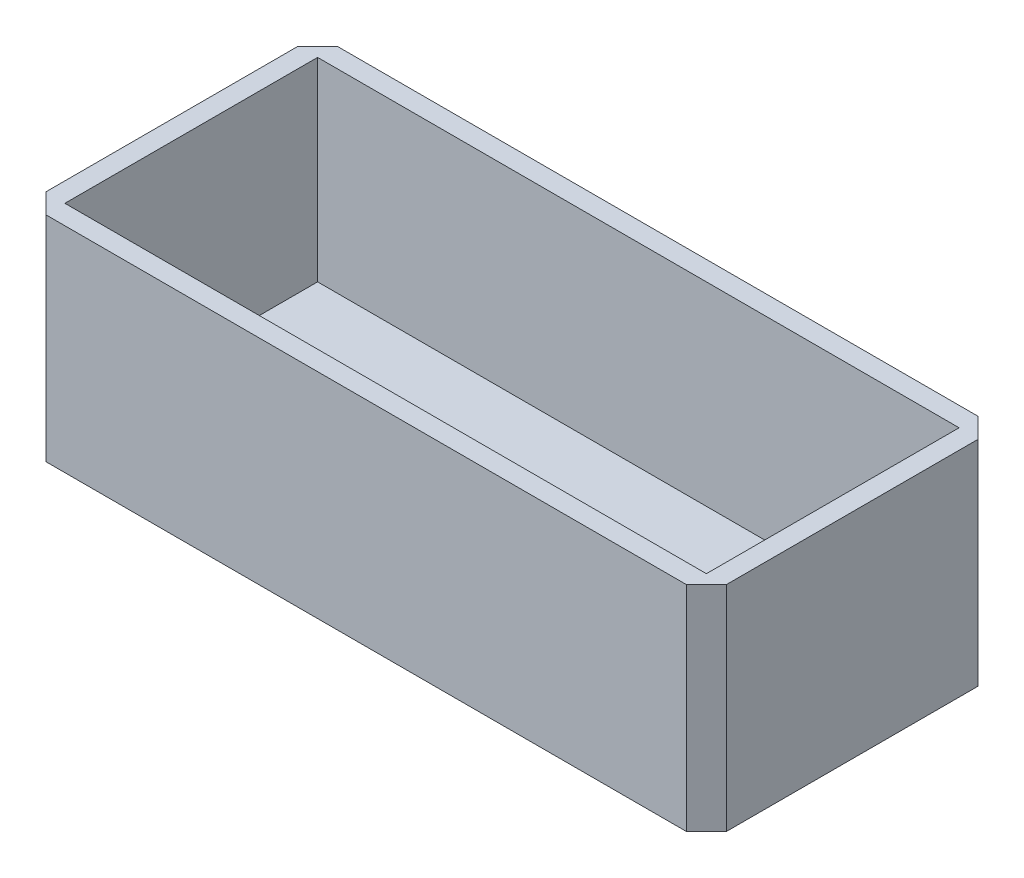
from build123d import *

# Parameters (mm, degrees)
CROQUIS1_W              = 70
CROQUIS1_H              = 30
SALIENTE_EXTRUIR1_DEPTH = 22
VACIADO1_T              = -2
CORTAR_EXTRUIR1_DEPTH   = 22
CORTAR_EXTRUIR3_DEPTH   = 22


with BuildPart() as part:
    # Croquis1 → Saliente-Extruir1 (new body)
    with BuildSketch(Plane(origin=(0, 0, 0), x_dir=(1, 0, 0), z_dir=(0, 1, 0))):
        with Locations((35, 15)):
            Rectangle(CROQUIS1_W, CROQUIS1_H)
    extrude(amount=SALIENTE_EXTRUIR1_DEPTH)

    # Vaciado1
    vaciado1_openings = [part.faces().sort_by_distance(p)[0] for p in [
        (35, 22, -15),
    ]]
    offset(amount=VACIADO1_T, openings=vaciado1_openings, kind=Kind.INTERSECTION)

    # Croquis2 → Cortar-Extruir1 (cut)
    with BuildSketch(Plane(origin=(0, 2, 0), x_dir=(1, 0, 0), z_dir=(0, 1, 0))):
        with BuildLine():
            Line((60, 17), (50, 17))
            ThreePointArc((50, 17), (48, 15), (50, 13))
            Line((50, 13), (60, 13))
            ThreePointArc((60, 13), (62, 15), (60, 17))
        make_face()
        with BuildLine():
            Line((10, 17), (20, 17))
            ThreePointArc((20, 17), (22, 15), (20, 13))
            Line((20, 13), (10, 13))
            ThreePointArc((10, 13), (8, 15), (10, 17))
        make_face()
    extrude(amount=-CORTAR_EXTRUIR1_DEPTH, mode=Mode.SUBTRACT)

    # Croquis3 → Cortar-Extruir3 (cut)
    with BuildSketch(Plane(origin=(0, 22, 0), x_dir=(1, 0, 0), z_dir=(0, 1, 0))):
        Polygon((2.056887166, 0), (0, 2.056887166), (0, 0), align=None)
        Polygon((70, 0), (70, 2.056887166), (67.943112834, 0), align=None)
        Polygon((70, 30), (67.943112834, 30), (70, 27.943112834), align=None)
        Polygon((0, 30), (2.056887166, 30), (0, 27.943112834), align=None)
    extrude(amount=-CORTAR_EXTRUIR3_DEPTH, mode=Mode.SUBTRACT)


solid = part.part
